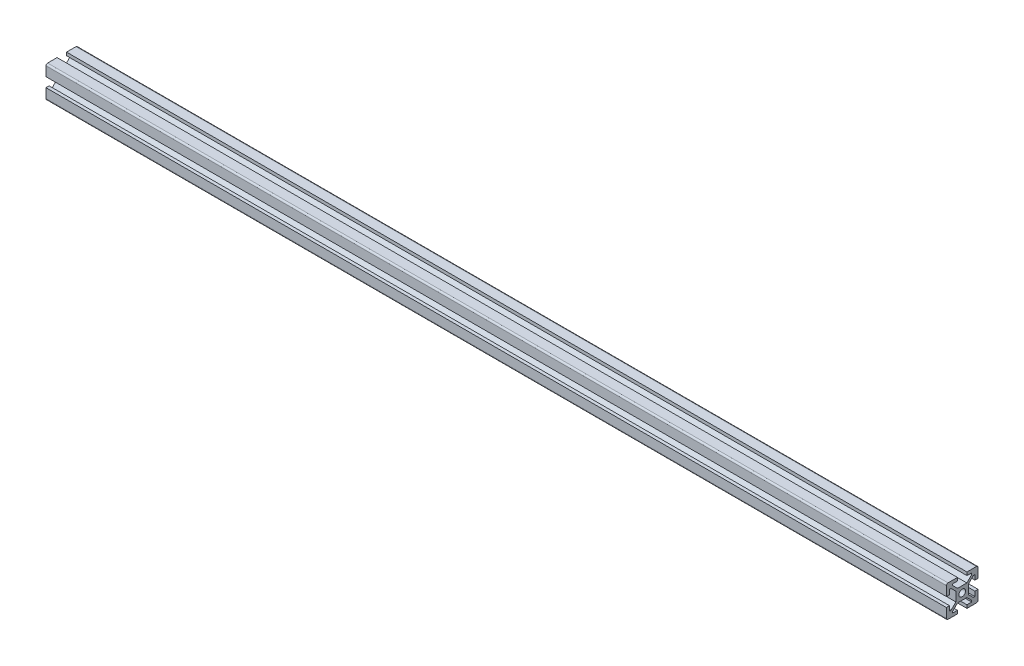
from build123d import *

# Parameters (mm, degrees)
SKETCH1_R           = 2.1
BOSS_EXTRUDE1_DEPTH = 570


with BuildPart() as part:
    # Sketch1 → Boss-Extrude1 (new body)
    with BuildSketch(Plane(origin=(0, 0, 0), x_dir=(0, 0, -1), z_dir=(1, 0, 0))):
        with BuildLine():
            Line((-10, 9), (-10, 3))
            Line((-10, 3), (-8, 3))
            Line((-8, 3), (-8, 6))
            Line((-8, 6), (-7.060660172, 6))
            Line((-7.060660172, 6), (-4, 2.939339828))
            Line((-4, 2.939339828), (-4, -2.939339828))
            Line((-4, -2.939339828), (-7.060660172, -6))
            Line((-7.060660172, -6), (-8, -6))
            Line((-8, -6), (-8, -3))
            Line((-8, -3), (-10, -3))
            Line((-10, -3), (-10, -9))
            ThreePointArc((-10, -9), (-9.707106781, -9.707106781), (-9, -10))
            Line((-9, -10), (-3, -10))
            Line((-3, -10), (-3, -8))
            Line((-3, -8), (-6, -8))
            Line((-6, -8), (-6, -7.060660172))
            Line((-6, -7.060660172), (-2.939339828, -4))
            Line((-2.939339828, -4), (2.939339828, -4))
            Line((2.939339828, -4), (6, -7.060660172))
            Line((6, -7.060660172), (6, -8))
            Line((6, -8), (3, -8))
            Line((3, -8), (3, -10))
            Line((3, -10), (9, -10))
            ThreePointArc((9, -10), (9.707106781, -9.707106781), (10, -9))
            Line((10, -9), (10, -3))
            Line((10, -3), (8, -3))
            Line((8, -3), (8, -6))
            Line((8, -6), (7.060660172, -6))
            Line((7.060660172, -6), (4, -2.939339828))
            Line((4, -2.939339828), (4, 2.939339828))
            Line((4, 2.939339828), (7.060660172, 6))
            Line((7.060660172, 6), (8, 6))
            Line((8, 6), (8, 3))
            Line((8, 3), (10, 3))
            Line((10, 3), (10, 9))
            ThreePointArc((10, 9), (9.707106781, 9.707106781), (9, 10))
            Line((9, 10), (3, 10))
            Line((3, 10), (3, 8))
            Line((3, 8), (6, 8))
            Line((6, 8), (6, 7.060660172))
            Line((6, 7.060660172), (2.939339828, 4))
            Line((2.939339828, 4), (-2.939339828, 4))
            Line((-2.939339828, 4), (-6, 7.060660172))
            Line((-6, 7.060660172), (-6, 8))
            Line((-6, 8), (-3, 8))
            Line((-3, 8), (-3, 10))
            Line((-3, 10), (-9, 10))
            ThreePointArc((-9, 10), (-9.707106781, 9.707106781), (-10, 9))
        make_face()
        Circle(SKETCH1_R, mode=Mode.SUBTRACT)
    extrude(amount=BOSS_EXTRUDE1_DEPTH)


solid = part.part
